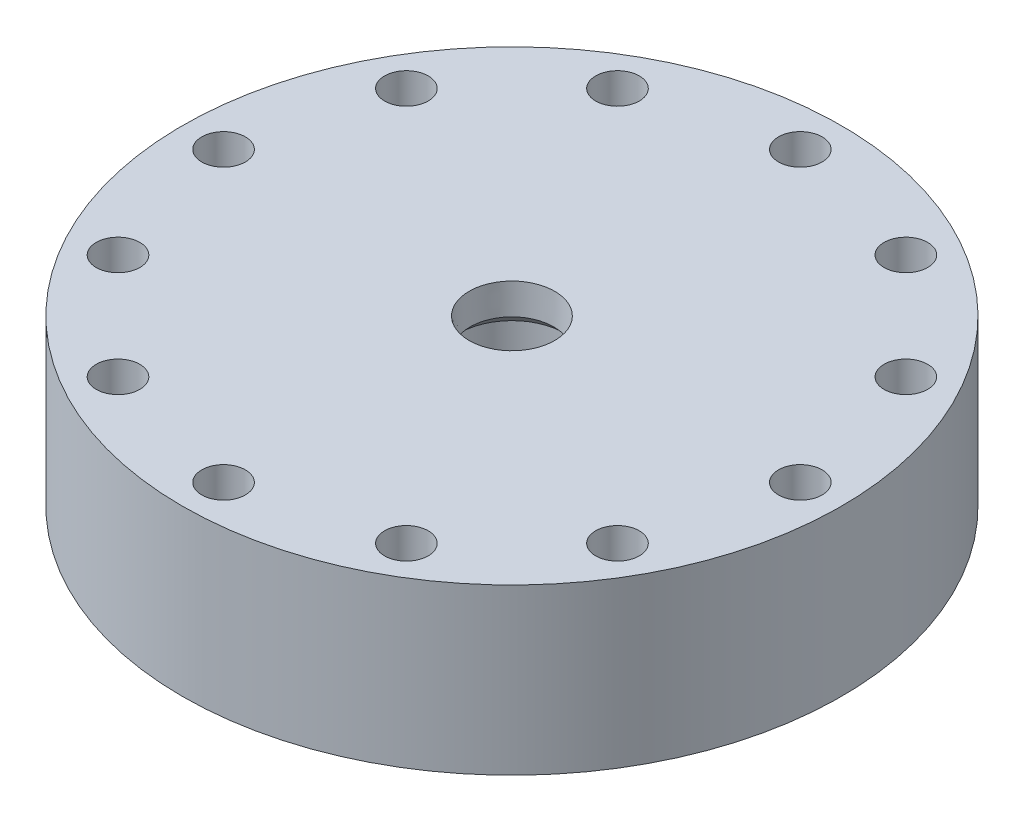
from build123d import *

# Parameters (mm, degrees)
F_3_64_0_04688_DIAMETER_HOLE2_AT_2_COUNT = 2
F_3_64_0_04688_DIAMETER_HOLE2_AT_2_PITCH = 4.490128061
CIRPATTERN6_COUNT                        = 3
LPATTERN1_COUNT                          = 2
LPATTERN1_PITCH                          = 25.4
F_3_64_0_04688_DIAMETER_HOLE3_AT_2_COUNT = 2
F_3_64_0_04688_DIAMETER_HOLE3_AT_2_PITCH = 4.490128061
CIRPATTERN7_COUNT                        = 3
CUT_EXTRUDE3_DEPTH                       = 9.525
CIRPATTERN8_COUNT                        = 6
CUT_EXTRUDE1_DEPTH                       = 34.925
CIRPATTERN5_COUNT                        = 6
F_3_8_CLEARANCE_HOLE1_D                  = 10.0838
CIRPATTERN4_COUNT                        = 12


with BuildPart() as part:
    # Sketch1 → Revolve1 (revolve)
    with BuildSketch(Plane.XY):
        Polygon((-76.2, 38.1), (0, 38.1), (0, 0), (-46.0375, 0), (-46.0375, 15.875), (-52.3875, 9.525), (-52.3875, 0), (-76.2, 0), align=None)
    revolve(axis=Axis((0, 38.1, 0), (0, -1, 0)))

    # Sketch12 → Cut-Revolve2 (revolve, cut)
    with BuildSketch(Plane.XY):
        Polygon((-0.79375, 23.834500899), (-7.14375, 17.484500899), (-10.506584126, 17.484500899), (-12.245554445, 19.223471218), (-12.245554445, 28.495737605), (-7.18475643, 33.55653562), (-0.79375, 27.16552919), align=None)
    revolve(axis=Axis((0, 74.05, 0), (0, -1, 0)), mode=Mode.SUBTRACT)

    # Sketch26 → Cut-Revolve3 (revolve, cut)
    with BuildSketch(Plane.XY):
        Polygon((0, 0), (0, 22.225), (-6.35, 15.875), (-6.35, 9.525), (-3.175, 6.35), (-3.175, 0), align=None)
        Polygon((-4.191, 0), (-4.191, 5.929159021), (-7.366, 9.104159021), (-7.366, 12.429818041), (-9.398, 14.461818041), (-9.398, 9.699318041), (-4.953, 5.254318041), (-4.953, 0), align=None)
    cut_revolve3 = revolve(axis=Axis((0, 74.05, 0), (0, -1, 0)), mode=Mode.SUBTRACT)

    # Sketch31 → 3_64 _0.04688_ Diameter Hole2 (revolve, cut)
    with BuildSketch(Plane(origin=(-8.73125, 11.90625, 0), x_dir=(0, 1, 0), z_dir=(1, 0, 0))):
        Polygon((0, 0), (0, 9.882737992), (0.595376, 9.525), (0.595376, 0), align=None)
    f_3_64_0_04688_diameter_hole2 = revolve(axis=Axis((-8.73125, 11.90625, -6.35), (0, 0, 1)), mode=Mode.SUBTRACT)

    # 3_64 _0.04688_ Diameter Hole2 at 2: 3_64 _0.04688_ Diameter Hole2 ×2
    with Locations(*[Vector(0.7071067811865475, 0.7071067811865477, 0) * (i * F_3_64_0_04688_DIAMETER_HOLE2_AT_2_PITCH) for i in range(1, F_3_64_0_04688_DIAMETER_HOLE2_AT_2_COUNT)]):
        add(f_3_64_0_04688_diameter_hole2, mode=Mode.SUBTRACT)

    # CirPattern6: 3_64 _0.04688_ Diameter Hole2 ×3 about axis
    cirpattern6_axis = Axis((0, 74.05, 0), (0, -1, 0))
    for i in range(1, CIRPATTERN6_COUNT):
        add(f_3_64_0_04688_diameter_hole2.rotate(cirpattern6_axis, i * 360 / CIRPATTERN6_COUNT), mode=Mode.SUBTRACT)

    # CirPattern6 copy 1 sketch → CirPattern6 copy 1 (revolve, cut)
    with BuildSketch(Plane(origin=(2.778125, 15.08125, -4.81185365), x_dir=(0, 1, 0), z_dir=(-0.4999999999999998, 0, 0.8660254037844387))):
        Polygon((0, 0), (0, 9.882737992), (0.595376, 9.525), (0.595376, 0), align=None)
    revolve(axis=Axis((8.277386314, 15.08125, -1.63685365), (-0.8660254037844387, 0, -0.4999999999999998)), mode=Mode.SUBTRACT)

    # CirPattern6 copy 2 sketch → CirPattern6 copy 2 (revolve, cut)
    with BuildSketch(Plane(origin=(2.778125, 15.08125, 4.81185365), x_dir=(0, 1, 0), z_dir=(-0.5000000000000004, 0, -0.8660254037844384))):
        Polygon((0, 0), (0, 9.882737992), (0.595376, 9.525), (0.595376, 0), align=None)
    revolve(axis=Axis((-2.721136314, 15.08125, 7.98685365), (0.8660254037844384, 0, -0.5000000000000004)), mode=Mode.SUBTRACT)

    # LPattern1: Cut-Revolve3 ×2
    with Locations(*[(i * LPATTERN1_PITCH, 0, 0) for i in range(1, LPATTERN1_COUNT)]):
        add(cut_revolve3, mode=Mode.SUBTRACT)

    # Sketch35 → 3_64 _0.04688_ Diameter Hole3 (revolve, cut)
    with BuildSketch(Plane(origin=(19.84375, 15.08125, 0), x_dir=(0, 1, 0), z_dir=(1, 0, 0))):
        Polygon((0, 0), (0, 9.882737992), (0.595376, 9.525), (0.595376, 0), align=None)
    f_3_64_0_04688_diameter_hole3 = revolve(axis=Axis((19.84375, 15.08125, -6.35), (0, 0, 1)), mode=Mode.SUBTRACT)

    # 3_64 _0.04688_ Diameter Hole3 at 2: 3_64 _0.04688_ Diameter Hole3 ×2
    with Locations(*[Vector(-0.7071067811865476, -0.7071067811865476, 0) * (i * F_3_64_0_04688_DIAMETER_HOLE3_AT_2_PITCH) for i in range(1, F_3_64_0_04688_DIAMETER_HOLE3_AT_2_COUNT)]):
        add(f_3_64_0_04688_diameter_hole3, mode=Mode.SUBTRACT)

    # CirPattern7: 3_64 _0.04688_ Diameter Hole3 ×3 about axis
    cirpattern7_axis = Axis((25.4, 0, 0), (0, 1, 0))
    for i in range(1, CIRPATTERN7_COUNT):
        add(f_3_64_0_04688_diameter_hole3.rotate(cirpattern7_axis, i * 360 / CIRPATTERN7_COUNT), mode=Mode.SUBTRACT)

    # CirPattern7 copy 1 sketch → CirPattern7 copy 1 (revolve, cut)
    with BuildSketch(Plane(origin=(29.765625, 11.90625, 7.561484307), x_dir=(0, 1, 0), z_dir=(-0.4999999999999998, 0, -0.8660254037844387))):
        Polygon((0, 0), (0, 9.882737992), (0.595376, 9.525), (0.595376, 0), align=None)
    revolve(axis=Axis((24.266363686, 11.90625, 10.736484307), (0.8660254037844387, 0, -0.4999999999999998)), mode=Mode.SUBTRACT)

    # CirPattern7 copy 2 sketch → CirPattern7 copy 2 (revolve, cut)
    with BuildSketch(Plane(origin=(29.765625, 11.90625, -7.561484307), x_dir=(0, 1, 0), z_dir=(-0.5000000000000004, 0, 0.8660254037844384))):
        Polygon((0, 0), (0, 9.882737992), (0.595376, 9.525), (0.595376, 0), align=None)
    revolve(axis=Axis((35.264886314, 11.90625, -4.386484307), (-0.8660254037844384, 0, -0.5000000000000004)), mode=Mode.SUBTRACT)

    # Sketch38 → Cut-Extrude3 (cut)
    with BuildSketch(Plane(origin=(45.862313413, 0, 4.012432507), x_dir=(0, 1, 0), z_dir=(0.9961946980917467, 0, 0.08715574274764504))):
        with BuildLine():
            Line((12.796298023, 1.683798023), (14.480096045, 0))
            Line((14.480096045, 0), (12.796298023, -1.683798023))
            ThreePointArc((12.796298023, -1.683798023), (8.73125, 0), (12.796298023, 1.683798023))
        make_face()
    cut_extrude3 = extrude(amount=-CUT_EXTRUDE3_DEPTH, mode=Mode.SUBTRACT)

    # CirPattern8: Cut-Extrude3 ×6 about axis
    cirpattern8_axis = Axis((0, 74.05, 0), (0, -1, 0))
    for i in range(1, CIRPATTERN8_COUNT):
        add(cut_extrude3.rotate(cirpattern8_axis, i * 360 / CIRPATTERN8_COUNT), mode=Mode.SUBTRACT)

    # Sketch27 → Cut-Extrude1 (cut)
    with BuildSketch(Plane(origin=(39.869644527, 0, -23.01875), x_dir=(0, 1, 0), z_dir=(0.866025403784438, 0, -0.500000000000001))):
        with BuildLine():
            Line((9.699318041, -2.38125), (11.90625, -2.38125))
            Line((11.90625, -2.38125), (14.2875, 0))
            Line((14.2875, 0), (11.90625, 2.38125))
            Line((11.90625, 2.38125), (9.699318041, 2.38125))
            ThreePointArc((9.699318041, 2.38125), (7.9375, 0), (9.699318041, -2.38125))
        make_face()
    cut_extrude1 = extrude(amount=-CUT_EXTRUDE1_DEPTH, mode=Mode.SUBTRACT)

    # CirPattern5: Cut-Extrude1 ×6 about axis
    cirpattern5_axis = Axis((0, 74.05, 0), (0, -1, 0))
    for i in range(1, CIRPATTERN5_COUNT):
        add(cut_extrude1.rotate(cirpattern5_axis, i * 360 / CIRPATTERN5_COUNT), mode=Mode.SUBTRACT)

    # CirPattern5 copy 1 sketch → CirPattern5 copy 1 (revolve, cut)
    with BuildSketch(Plane(origin=(12.7, 0, 21.997045256), x_dir=(0.5000000000000001, 0, 0.8660254037844386), z_dir=(-0.8660254037844386, 0, 0.5000000000000001))):
        Polygon((0, 0), (0, 22.225), (-6.35, 15.875), (-6.35, 9.525), (-3.175, 6.35), (-3.175, 0), align=None)
        Polygon((-4.191, 0), (-4.191, 5.929159021), (-7.366, 9.104159021), (-7.366, 12.429818041), (-9.398, 14.461818041), (-9.398, 9.699318041), (-4.953, 5.254318041), (-4.953, 0), align=None)
    revolve(axis=Axis((12.7, 74.05, 21.997045256), (0, -1, 0)), mode=Mode.SUBTRACT)

    # CirPattern5 copy 2 sketch → CirPattern5 copy 2 (revolve, cut)
    with BuildSketch(Plane(origin=(-12.7, 0, 21.997045256), x_dir=(-0.4999999999999998, 0, 0.8660254037844387), z_dir=(-0.8660254037844387, 0, -0.4999999999999998))):
        Polygon((0, 0), (0, 22.225), (-6.35, 15.875), (-6.35, 9.525), (-3.175, 6.35), (-3.175, 0), align=None)
        Polygon((-4.191, 0), (-4.191, 5.929159021), (-7.366, 9.104159021), (-7.366, 12.429818041), (-9.398, 14.461818041), (-9.398, 9.699318041), (-4.953, 5.254318041), (-4.953, 0), align=None)
    revolve(axis=Axis((-12.7, 74.05, 21.997045256), (0, -1, 0)), mode=Mode.SUBTRACT)

    # CirPattern5 copy 3 sketch → CirPattern5 copy 3 (revolve, cut)
    with BuildSketch(Plane(origin=(-25.4, 0, 0), x_dir=(-1, 0, 0), z_dir=(0, 0, -1))):
        Polygon((0, 0), (0, 22.225), (-6.35, 15.875), (-6.35, 9.525), (-3.175, 6.35), (-3.175, 0), align=None)
        Polygon((-4.191, 0), (-4.191, 5.929159021), (-7.366, 9.104159021), (-7.366, 12.429818041), (-9.398, 14.461818041), (-9.398, 9.699318041), (-4.953, 5.254318041), (-4.953, 0), align=None)
    revolve(axis=Axis((-25.4, 74.05, 0), (0, -1, 0)), mode=Mode.SUBTRACT)

    # CirPattern5 copy 4 sketch → CirPattern5 copy 4 (revolve, cut)
    with BuildSketch(Plane(origin=(-12.7, 0, -21.997045256), x_dir=(-0.5000000000000004, 0, -0.8660254037844384), z_dir=(0.8660254037844384, 0, -0.5000000000000004))):
        Polygon((0, 0), (0, 22.225), (-6.35, 15.875), (-6.35, 9.525), (-3.175, 6.35), (-3.175, 0), align=None)
        Polygon((-4.191, 0), (-4.191, 5.929159021), (-7.366, 9.104159021), (-7.366, 12.429818041), (-9.398, 14.461818041), (-9.398, 9.699318041), (-4.953, 5.254318041), (-4.953, 0), align=None)
    revolve(axis=Axis((-12.7, 74.05, -21.997045256), (0, -1, 0)), mode=Mode.SUBTRACT)

    # CirPattern5 copy 5 sketch → CirPattern5 copy 5 (revolve, cut)
    with BuildSketch(Plane(origin=(12.7, 0, -21.997045256), x_dir=(0.5000000000000001, 0, -0.8660254037844386), z_dir=(0.8660254037844386, 0, 0.5000000000000001))):
        Polygon((0, 0), (0, 22.225), (-6.35, 15.875), (-6.35, 9.525), (-3.175, 6.35), (-3.175, 0), align=None)
        Polygon((-4.191, 0), (-4.191, 5.929159021), (-7.366, 9.104159021), (-7.366, 12.429818041), (-9.398, 14.461818041), (-9.398, 9.699318041), (-4.953, 5.254318041), (-4.953, 0), align=None)
    revolve(axis=Axis((12.7, 74.05, -21.997045256), (0, -1, 0)), mode=Mode.SUBTRACT)

    # CirPattern5 copy 6 sketch → CirPattern5 copy 6 (revolve, cut)
    with BuildSketch(Plane(origin=(0, 0, 0), x_dir=(0.5000000000000001, 0, 0.8660254037844386), z_dir=(-0.8660254037844386, 0, 0.5000000000000001))):
        Polygon((0, 0), (0, 22.225), (-6.35, 15.875), (-6.35, 9.525), (-3.175, 6.35), (-3.175, 0), align=None)
        Polygon((-4.191, 0), (-4.191, 5.929159021), (-7.366, 9.104159021), (-7.366, 12.429818041), (-9.398, 14.461818041), (-9.398, 9.699318041), (-4.953, 5.254318041), (-4.953, 0), align=None)
    revolve(axis=Axis((0, 74.05, 0), (0, -1, 0)), mode=Mode.SUBTRACT)

    # CirPattern5 copy 7 sketch → CirPattern5 copy 7 (revolve, cut)
    with BuildSketch(Plane(origin=(0, 0, 0), x_dir=(-0.4999999999999998, 0, 0.8660254037844387), z_dir=(-0.8660254037844387, 0, -0.4999999999999998))):
        Polygon((0, 0), (0, 22.225), (-6.35, 15.875), (-6.35, 9.525), (-3.175, 6.35), (-3.175, 0), align=None)
        Polygon((-4.191, 0), (-4.191, 5.929159021), (-7.366, 9.104159021), (-7.366, 12.429818041), (-9.398, 14.461818041), (-9.398, 9.699318041), (-4.953, 5.254318041), (-4.953, 0), align=None)
    revolve(axis=Axis((0, 74.05, 0), (0, -1, 0)), mode=Mode.SUBTRACT)

    # CirPattern5 copy 8 sketch → CirPattern5 copy 8 (revolve, cut)
    with BuildSketch(Plane(origin=(0, 0, 0), x_dir=(-1, 0, 0), z_dir=(0, 0, -1))):
        Polygon((0, 0), (0, 22.225), (-6.35, 15.875), (-6.35, 9.525), (-3.175, 6.35), (-3.175, 0), align=None)
        Polygon((-4.191, 0), (-4.191, 5.929159021), (-7.366, 9.104159021), (-7.366, 12.429818041), (-9.398, 14.461818041), (-9.398, 9.699318041), (-4.953, 5.254318041), (-4.953, 0), align=None)
    revolve(axis=Axis((0, 74.05, 0), (0, -1, 0)), mode=Mode.SUBTRACT)

    # CirPattern5 copy 9 sketch → CirPattern5 copy 9 (revolve, cut)
    with BuildSketch(Plane(origin=(0, 0, 0), x_dir=(-0.5000000000000004, 0, -0.8660254037844384), z_dir=(0.8660254037844384, 0, -0.5000000000000004))):
        Polygon((0, 0), (0, 22.225), (-6.35, 15.875), (-6.35, 9.525), (-3.175, 6.35), (-3.175, 0), align=None)
        Polygon((-4.191, 0), (-4.191, 5.929159021), (-7.366, 9.104159021), (-7.366, 12.429818041), (-9.398, 14.461818041), (-9.398, 9.699318041), (-4.953, 5.254318041), (-4.953, 0), align=None)
    revolve(axis=Axis((0, 74.05, 0), (0, -1, 0)), mode=Mode.SUBTRACT)

    # CirPattern5 copy 10 sketch → CirPattern5 copy 10 (revolve, cut)
    with BuildSketch(Plane(origin=(0, 0, 0), x_dir=(0.5000000000000001, 0, -0.8660254037844386), z_dir=(0.8660254037844386, 0, 0.5000000000000001))):
        Polygon((0, 0), (0, 22.225), (-6.35, 15.875), (-6.35, 9.525), (-3.175, 6.35), (-3.175, 0), align=None)
        Polygon((-4.191, 0), (-4.191, 5.929159021), (-7.366, 9.104159021), (-7.366, 12.429818041), (-9.398, 14.461818041), (-9.398, 9.699318041), (-4.953, 5.254318041), (-4.953, 0), align=None)
    revolve(axis=Axis((0, 74.05, 0), (0, -1, 0)), mode=Mode.SUBTRACT)

    # CirPattern5 copy 11 sketch → CirPattern5 copy 11 (revolve, cut)
    with BuildSketch(Plane(origin=(9.921875, 15.08125, 26.808898906), x_dir=(0, 1, 0), z_dir=(0.5, 0, -0.8660254037844386))):
        Polygon((0, 0), (0, 9.882737992), (0.595376, 9.525), (0.595376, 0), align=None)
    revolve(axis=Axis((4.422613686, 15.08125, 23.633898906), (0.8660254037844386, 0, 0.5)), mode=Mode.SUBTRACT)

    # CirPattern5 copy 12 sketch → CirPattern5 copy 12 (revolve, cut)
    with BuildSketch(Plane(origin=(-18.25625, 15.08125, 21.997045256), x_dir=(0, 1, 0), z_dir=(1, 0, 0))):
        Polygon((0, 0), (0, 9.882737992), (0.595376, 9.525), (0.595376, 0), align=None)
    revolve(axis=Axis((-18.25625, 15.08125, 15.647045256), (0, 0, 1)), mode=Mode.SUBTRACT)

    # CirPattern5 copy 13 sketch → CirPattern5 copy 13 (revolve, cut)
    with BuildSketch(Plane(origin=(-28.178125, 15.08125, -4.81185365), x_dir=(0, 1, 0), z_dir=(0.4999999999999999, 0, 0.8660254037844386))):
        Polygon((0, 0), (0, 9.882737992), (0.595376, 9.525), (0.595376, 0), align=None)
    revolve(axis=Axis((-22.678863686, 15.08125, -7.98685365), (-0.8660254037844386, 0, 0.4999999999999999)), mode=Mode.SUBTRACT)

    # CirPattern5 copy 14 sketch → CirPattern5 copy 14 (revolve, cut)
    with BuildSketch(Plane(origin=(-9.921875, 15.08125, -26.808898906), x_dir=(0, 1, 0), z_dir=(-0.49999999999999967, 0, 0.8660254037844388))):
        Polygon((0, 0), (0, 9.882737992), (0.595376, 9.525), (0.595376, 0), align=None)
    revolve(axis=Axis((-4.422613686, 15.08125, -23.633898906), (-0.8660254037844388, 0, -0.49999999999999967)), mode=Mode.SUBTRACT)

    # CirPattern5 copy 15 sketch → CirPattern5 copy 15 (revolve, cut)
    with BuildSketch(Plane(origin=(18.25625, 15.08125, -21.997045256), x_dir=(0, 1, 0), z_dir=(-1, 0, 0))):
        Polygon((0, 0), (0, 9.882737992), (0.595376, 9.525), (0.595376, 0), align=None)
    revolve(axis=Axis((18.25625, 15.08125, -15.647045256), (0, 0, -1)), mode=Mode.SUBTRACT)

    # CirPattern5 copy 16 sketch → CirPattern5 copy 16 (revolve, cut)
    with BuildSketch(Plane(origin=(18.25625, 15.08125, 21.997045256), x_dir=(0, 1, 0), z_dir=(-1, 0, 0))):
        Polygon((0, 0), (0, 9.882737992), (0.595376, 9.525), (0.595376, 0), align=None)
    revolve(axis=Axis((18.25625, 15.08125, 28.347045256), (0, 0, -1)), mode=Mode.SUBTRACT)

    # CirPattern5 copy 17 sketch → CirPattern5 copy 17 (revolve, cut)
    with BuildSketch(Plane(origin=(-9.921875, 15.08125, 26.808898906), x_dir=(0, 1, 0), z_dir=(-0.49999999999999967, 0, -0.8660254037844388))):
        Polygon((0, 0), (0, 9.882737992), (0.595376, 9.525), (0.595376, 0), align=None)
    revolve(axis=Axis((-15.421136314, 15.08125, 29.983898906), (0.8660254037844388, 0, -0.49999999999999967)), mode=Mode.SUBTRACT)

    # CirPattern5 copy 18 sketch → CirPattern5 copy 18 (revolve, cut)
    with BuildSketch(Plane(origin=(-28.178125, 15.08125, 4.81185365), x_dir=(0, 1, 0), z_dir=(0.5000000000000003, 0, -0.8660254037844385))):
        Polygon((0, 0), (0, 9.882737992), (0.595376, 9.525), (0.595376, 0), align=None)
    revolve(axis=Axis((-33.677386314, 15.08125, 1.63685365), (0.8660254037844385, 0, 0.5000000000000003)), mode=Mode.SUBTRACT)

    # CirPattern5 copy 19 sketch → CirPattern5 copy 19 (revolve, cut)
    with BuildSketch(Plane(origin=(-18.25625, 15.08125, -21.997045256), x_dir=(0, 1, 0), z_dir=(1, 0, 0))):
        Polygon((0, 0), (0, 9.882737992), (0.595376, 9.525), (0.595376, 0), align=None)
    revolve(axis=Axis((-18.25625, 15.08125, -28.347045256), (0, 0, 1)), mode=Mode.SUBTRACT)

    # CirPattern5 copy 20 sketch → CirPattern5 copy 20 (revolve, cut)
    with BuildSketch(Plane(origin=(9.921875, 15.08125, -26.808898906), x_dir=(0, 1, 0), z_dir=(0.4999999999999994, 0, 0.866025403784439))):
        Polygon((0, 0), (0, 9.882737992), (0.595376, 9.525), (0.595376, 0), align=None)
    revolve(axis=Axis((15.421136314, 15.08125, -29.983898906), (-0.866025403784439, 0, 0.4999999999999994)), mode=Mode.SUBTRACT)

    # CirPattern5 copy 21 sketch → CirPattern5 copy 21 (revolve, cut)
    with BuildSketch(Plane(origin=(8.334375, 11.90625, 29.558529563), x_dir=(0, 1, 0), z_dir=(0.5, 0, -0.8660254037844386))):
        Polygon((0, 0), (0, 9.882737992), (0.595376, 9.525), (0.595376, 0), align=None)
    revolve(axis=Axis((2.835113686, 11.90625, 26.383529563), (0.8660254037844386, 0, 0.5)), mode=Mode.SUBTRACT)

    # CirPattern5 copy 22 sketch → CirPattern5 copy 22 (revolve, cut)
    with BuildSketch(Plane(origin=(-21.43125, 11.90625, 21.997045256), x_dir=(0, 1, 0), z_dir=(1, 0, 0))):
        Polygon((0, 0), (0, 9.882737992), (0.595376, 9.525), (0.595376, 0), align=None)
    revolve(axis=Axis((-21.43125, 11.90625, 15.647045256), (0, 0, 1)), mode=Mode.SUBTRACT)

    # CirPattern5 copy 23 sketch → CirPattern5 copy 23 (revolve, cut)
    with BuildSketch(Plane(origin=(-29.765625, 11.90625, -7.561484307), x_dir=(0, 1, 0), z_dir=(0.4999999999999999, 0, 0.8660254037844386))):
        Polygon((0, 0), (0, 9.882737992), (0.595376, 9.525), (0.595376, 0), align=None)
    revolve(axis=Axis((-24.266363686, 11.90625, -10.736484307), (-0.8660254037844386, 0, 0.4999999999999999)), mode=Mode.SUBTRACT)

    # CirPattern5 copy 24 sketch → CirPattern5 copy 24 (revolve, cut)
    with BuildSketch(Plane(origin=(-8.334375, 11.90625, -29.558529563), x_dir=(0, 1, 0), z_dir=(-0.49999999999999967, 0, 0.8660254037844388))):
        Polygon((0, 0), (0, 9.882737992), (0.595376, 9.525), (0.595376, 0), align=None)
    revolve(axis=Axis((-2.835113686, 11.90625, -26.383529563), (-0.8660254037844388, 0, -0.49999999999999967)), mode=Mode.SUBTRACT)

    # CirPattern5 copy 25 sketch → CirPattern5 copy 25 (revolve, cut)
    with BuildSketch(Plane(origin=(21.43125, 11.90625, -21.997045256), x_dir=(0, 1, 0), z_dir=(-1, 0, 0))):
        Polygon((0, 0), (0, 9.882737992), (0.595376, 9.525), (0.595376, 0), align=None)
    revolve(axis=Axis((21.43125, 11.90625, -15.647045256), (0, 0, -1)), mode=Mode.SUBTRACT)

    # CirPattern5 copy 26 sketch → CirPattern5 copy 26 (revolve, cut)
    with BuildSketch(Plane(origin=(21.43125, 11.90625, 21.997045256), x_dir=(0, 1, 0), z_dir=(-1, 0, 0))):
        Polygon((0, 0), (0, 9.882737992), (0.595376, 9.525), (0.595376, 0), align=None)
    revolve(axis=Axis((21.43125, 11.90625, 28.347045256), (0, 0, -1)), mode=Mode.SUBTRACT)

    # CirPattern5 copy 27 sketch → CirPattern5 copy 27 (revolve, cut)
    with BuildSketch(Plane(origin=(-8.334375, 11.90625, 29.558529563), x_dir=(0, 1, 0), z_dir=(-0.49999999999999967, 0, -0.8660254037844388))):
        Polygon((0, 0), (0, 9.882737992), (0.595376, 9.525), (0.595376, 0), align=None)
    revolve(axis=Axis((-13.833636314, 11.90625, 32.733529563), (0.8660254037844388, 0, -0.49999999999999967)), mode=Mode.SUBTRACT)

    # CirPattern5 copy 28 sketch → CirPattern5 copy 28 (revolve, cut)
    with BuildSketch(Plane(origin=(-29.765625, 11.90625, 7.561484307), x_dir=(0, 1, 0), z_dir=(0.5000000000000003, 0, -0.8660254037844385))):
        Polygon((0, 0), (0, 9.882737992), (0.595376, 9.525), (0.595376, 0), align=None)
    revolve(axis=Axis((-35.264886314, 11.90625, 4.386484307), (0.8660254037844385, 0, 0.5000000000000003)), mode=Mode.SUBTRACT)

    # CirPattern5 copy 29 sketch → CirPattern5 copy 29 (revolve, cut)
    with BuildSketch(Plane(origin=(-21.43125, 11.90625, -21.997045256), x_dir=(0, 1, 0), z_dir=(1, 0, 0))):
        Polygon((0, 0), (0, 9.882737992), (0.595376, 9.525), (0.595376, 0), align=None)
    revolve(axis=Axis((-21.43125, 11.90625, -28.347045256), (0, 0, 1)), mode=Mode.SUBTRACT)

    # CirPattern5 copy 30 sketch → CirPattern5 copy 30 (revolve, cut)
    with BuildSketch(Plane(origin=(8.334375, 11.90625, -29.558529563), x_dir=(0, 1, 0), z_dir=(0.4999999999999994, 0, 0.866025403784439))):
        Polygon((0, 0), (0, 9.882737992), (0.595376, 9.525), (0.595376, 0), align=None)
    revolve(axis=Axis((13.833636314, 11.90625, -32.733529563), (-0.866025403784439, 0, 0.4999999999999994)), mode=Mode.SUBTRACT)

    # CirPattern5 copy 31 sketch → CirPattern5 copy 31 (revolve, cut)
    with BuildSketch(Plane(origin=(9.921875, 15.08125, 17.185191606), x_dir=(0, 1, 0), z_dir=(0.5000000000000001, 0, 0.8660254037844386))):
        Polygon((0, 0), (0, 9.882737992), (0.595376, 9.525), (0.595376, 0), align=None)
    revolve(axis=Axis((15.421136314, 15.08125, 14.010191606), (-0.8660254037844386, 0, 0.5000000000000001)), mode=Mode.SUBTRACT)

    # CirPattern5 copy 32 sketch → CirPattern5 copy 32 (revolve, cut)
    with BuildSketch(Plane(origin=(-9.921875, 15.08125, 17.185191606), x_dir=(0, 1, 0), z_dir=(-0.4999999999999998, 0, 0.8660254037844387))):
        Polygon((0, 0), (0, 9.882737992), (0.595376, 9.525), (0.595376, 0), align=None)
    revolve(axis=Axis((-4.422613686, 15.08125, 20.360191606), (-0.8660254037844387, 0, -0.4999999999999998)), mode=Mode.SUBTRACT)

    # CirPattern5 copy 33 sketch → CirPattern5 copy 33 (revolve, cut)
    with BuildSketch(Plane(origin=(-19.84375, 15.08125, 0), x_dir=(0, 1, 0), z_dir=(-1, 0, 0))):
        Polygon((0, 0), (0, 9.882737992), (0.595376, 9.525), (0.595376, 0), align=None)
    revolve(axis=Axis((-19.84375, 15.08125, 6.35), (0, 0, -1)), mode=Mode.SUBTRACT)

    # CirPattern5 copy 34 sketch → CirPattern5 copy 34 (revolve, cut)
    with BuildSketch(Plane(origin=(-9.921875, 15.08125, -17.185191606), x_dir=(0, 1, 0), z_dir=(-0.5000000000000004, 0, -0.8660254037844384))):
        Polygon((0, 0), (0, 9.882737992), (0.595376, 9.525), (0.595376, 0), align=None)
    revolve(axis=Axis((-15.421136314, 15.08125, -14.010191606), (0.8660254037844384, 0, -0.5000000000000004)), mode=Mode.SUBTRACT)

    # CirPattern5 copy 35 sketch → CirPattern5 copy 35 (revolve, cut)
    with BuildSketch(Plane(origin=(9.921875, 15.08125, -17.185191606), x_dir=(0, 1, 0), z_dir=(0.5000000000000001, 0, -0.8660254037844386))):
        Polygon((0, 0), (0, 9.882737992), (0.595376, 9.525), (0.595376, 0), align=None)
    revolve(axis=Axis((4.422613686, 15.08125, -20.360191606), (0.8660254037844386, 0, 0.5000000000000001)), mode=Mode.SUBTRACT)

    # CirPattern5 copy 36 sketch → CirPattern5 copy 36 (revolve, cut)
    with BuildSketch(Plane(origin=(8.334375, 11.90625, 14.435560949), x_dir=(0, 1, 0), z_dir=(0.5000000000000001, 0, 0.8660254037844386))):
        Polygon((0, 0), (0, 9.882737992), (0.595376, 9.525), (0.595376, 0), align=None)
    revolve(axis=Axis((13.833636314, 11.90625, 11.260560949), (-0.8660254037844386, 0, 0.5000000000000001)), mode=Mode.SUBTRACT)

    # CirPattern5 copy 37 sketch → CirPattern5 copy 37 (revolve, cut)
    with BuildSketch(Plane(origin=(-8.334375, 11.90625, 14.435560949), x_dir=(0, 1, 0), z_dir=(-0.4999999999999998, 0, 0.8660254037844387))):
        Polygon((0, 0), (0, 9.882737992), (0.595376, 9.525), (0.595376, 0), align=None)
    revolve(axis=Axis((-2.835113686, 11.90625, 17.610560949), (-0.8660254037844387, 0, -0.4999999999999998)), mode=Mode.SUBTRACT)

    # CirPattern5 copy 38 sketch → CirPattern5 copy 38 (revolve, cut)
    with BuildSketch(Plane(origin=(-16.66875, 11.90625, 0), x_dir=(0, 1, 0), z_dir=(-1, 0, 0))):
        Polygon((0, 0), (0, 9.882737992), (0.595376, 9.525), (0.595376, 0), align=None)
    revolve(axis=Axis((-16.66875, 11.90625, 6.35), (0, 0, -1)), mode=Mode.SUBTRACT)

    # CirPattern5 copy 39 sketch → CirPattern5 copy 39 (revolve, cut)
    with BuildSketch(Plane(origin=(-8.334375, 11.90625, -14.435560949), x_dir=(0, 1, 0), z_dir=(-0.5000000000000004, 0, -0.8660254037844384))):
        Polygon((0, 0), (0, 9.882737992), (0.595376, 9.525), (0.595376, 0), align=None)
    revolve(axis=Axis((-13.833636314, 11.90625, -11.260560949), (0.8660254037844384, 0, -0.5000000000000004)), mode=Mode.SUBTRACT)

    # CirPattern5 copy 40 sketch → CirPattern5 copy 40 (revolve, cut)
    with BuildSketch(Plane(origin=(8.334375, 11.90625, -14.435560949), x_dir=(0, 1, 0), z_dir=(0.5000000000000001, 0, -0.8660254037844386))):
        Polygon((0, 0), (0, 9.882737992), (0.595376, 9.525), (0.595376, 0), align=None)
    revolve(axis=Axis((2.835113686, 11.90625, -17.610560949), (0.8660254037844386, 0, 0.5000000000000001)), mode=Mode.SUBTRACT)

    # Sketch36 → Cut-Revolve6 (revolve, cut)
    with BuildSketch(Plane.XY):
        with BuildLine():
            Line((-12.7, 13.35756403), (-11.577467985, 12.235032015))
            ThreePointArc((-11.577467985, 12.235032015), (-12.7, 9.525), (-13.822532015, 12.235032015))
            Line((-13.822532015, 12.235032015), (-12.7, 13.35756403))
        make_face()
    revolve(axis=Axis((0, 74.05, 0), (0, -1, 0)), mode=Mode.SUBTRACT)

    # 3_8 Clearance Hole1 (through all)
    with Locations(Plane(origin=(0, 38.1, 0), x_dir=(1, 0, 0), z_dir=(0, 1, 0))):
        with Locations((66.675, 0)):
            f_3_8_clearance_hole1 = Hole(F_3_8_CLEARANCE_HOLE1_D / 2)

    # CirPattern4: 3_8 Clearance Hole1 ×12 about axis
    cirpattern4_axis = Axis((0, 74.05, 0), (0, -1, 0))
    for i in range(1, CIRPATTERN4_COUNT):
        add(f_3_8_clearance_hole1.rotate(cirpattern4_axis, i * 360 / CIRPATTERN4_COUNT), mode=Mode.SUBTRACT)

    # Sketch25 → 1_2 NPT Tapped Hole2 (revolve, cut)
    with BuildSketch(Plane(origin=(0, 38.1, 0), x_dir=(0, 0, 1), z_dir=(1, 0, 0))):
        Polygon((0, 0), (0, 21.239543693), (8.9281, 15.875), (8.9281, 13.462), (9.479726792, 13.462), (9.8827971, 0), align=None)
    revolve(axis=Axis((0, 44.45, 0), (0, -1, 0)), mode=Mode.SUBTRACT)

    # Sketch5 → 1_2 NPT Tapped Hole1 (revolve, cut)
    with BuildSketch(Plane(origin=(0, 38.1, 0), x_dir=(0, 0, 1), z_dir=(1, 0, 0))):
        Polygon((0, 0), (0, 24.414543693), (8.9281, 19.05), (8.9281, 13.462), (9.479726792, 13.462), (9.8827971, 0), align=None)
    revolve(axis=Axis((0, 44.45, 0), (0, -1, 0)), mode=Mode.SUBTRACT)


solid = part.part
